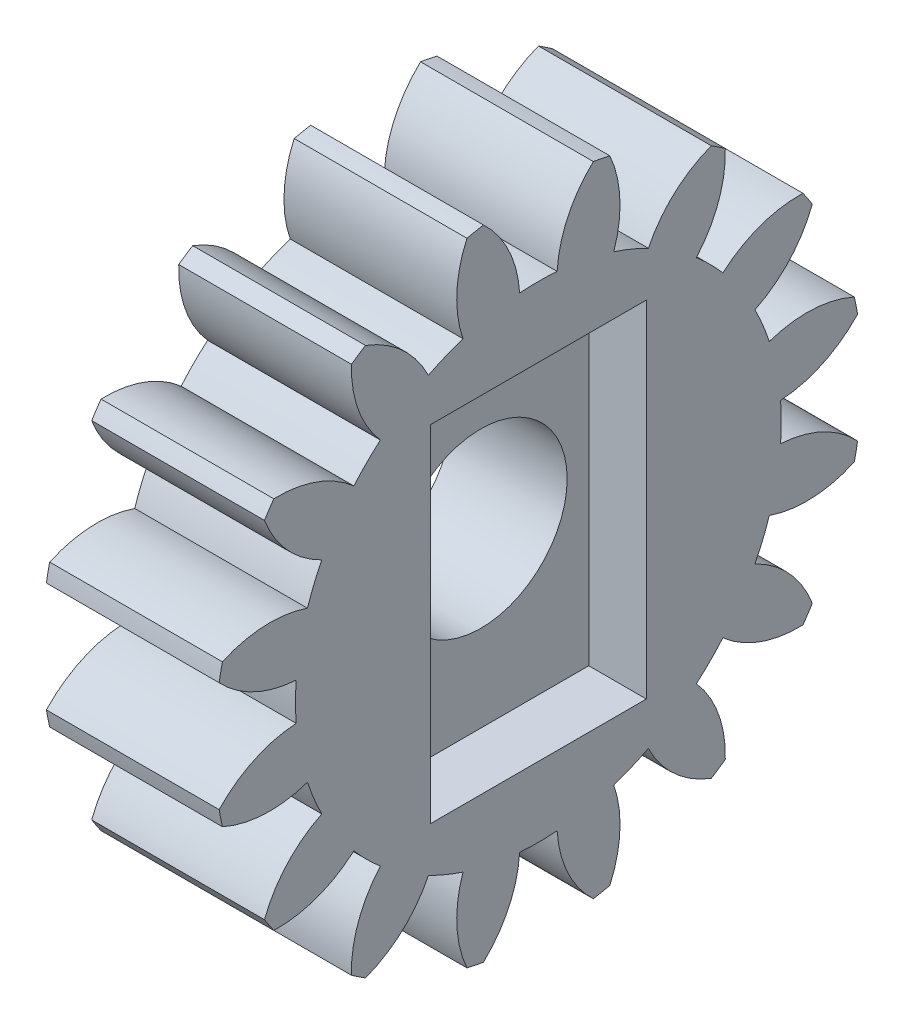
from build123d import *

# Parameters (mm, degrees)
BASPROSKE_W         = 6
BASPROSKE_H         = 11.25
TOOTHCUT_DEPTH      = 18.003676073
TEETHCUTS_COUNT     = 16
TEETHCUTS_ANGLE     = 337.5
BORSKE_R            = 3
BORE_DEPTH          = 50.0000508
SKETCH_1_W          = 7.5
SKETCH_1_H          = 12
CUT_EXTRUDE_1_DEPTH = 2


with BuildPart() as part:
    # BasProSke → Base-Revolve (revolve)
    with BuildSketch(Plane(origin=(0, 0, 0), x_dir=(1, 0, 0), z_dir=(0, 1, 0)), mode=Mode.PRIVATE) as base_revolve_sk:
        with Locations((3, 5.625)):
            Rectangle(BASPROSKE_W, BASPROSKE_H)
    revolve(base_revolve_sk.sketch.rotate(Axis((-10, 0, 0), (1, 0, 0)), 180), axis=Axis((-10, 0, 0), (1, 0, 0)))

    # TooCutSke → ToothCut (cut, through all)
    with BuildSketch(Plane(origin=(0, 0, 0), x_dir=(0, 0, -1), z_dir=(1, 0, 0))):
        with BuildLine():
            ThreePointArc((0.651061533, 8.411340626), (0, 8.4365), (-0.651061533, 8.411340626))
            ThreePointArc((-0.651061533, 8.411340626), (-1.029874156, 9.883978829), (-1.930926138, 11.108832945))
            ThreePointArc((-1.930926138, 11.108832945), (0, 11.2754), (1.930926138, 11.108832945))
            ThreePointArc((1.930926138, 11.108832945), (1.029874156, 9.883978829), (0.651061533, 8.411340626))
        make_face()
    toothcut = extrude(amount=TOOTHCUT_DEPTH, mode=Mode.SUBTRACT)

    # TeethCuts: ToothCut ×16 about axis
    teethcuts_axis = Axis((-10, 0, 0), (1, 0, 0))
    for i in range(1, TEETHCUTS_COUNT):
        add(toothcut.rotate(teethcuts_axis, i * TEETHCUTS_ANGLE / (TEETHCUTS_COUNT - 1)), mode=Mode.SUBTRACT)

    # BorSke → Bore (cut, symmetric)
    with BuildSketch(Plane(origin=(0, 0, 0), x_dir=(0, 0, -1), z_dir=(1, 0, 0))):
        with Locations(Location((0, 0, 0), (0, 0, 180))):
            Circle(BORSKE_R)
    extrude(amount=BORE_DEPTH, both=True, mode=Mode.SUBTRACT)

    # Эскиз1 → Вырез-Вытянуть1 (cut)
    with BuildSketch(Plane(origin=(6, 0, 0), x_dir=(0, 0, -1), z_dir=(1, 0, 0))):
        Rectangle(SKETCH_1_W, SKETCH_1_H)
    extrude(amount=-CUT_EXTRUDE_1_DEPTH, mode=Mode.SUBTRACT)


solid = part.part
